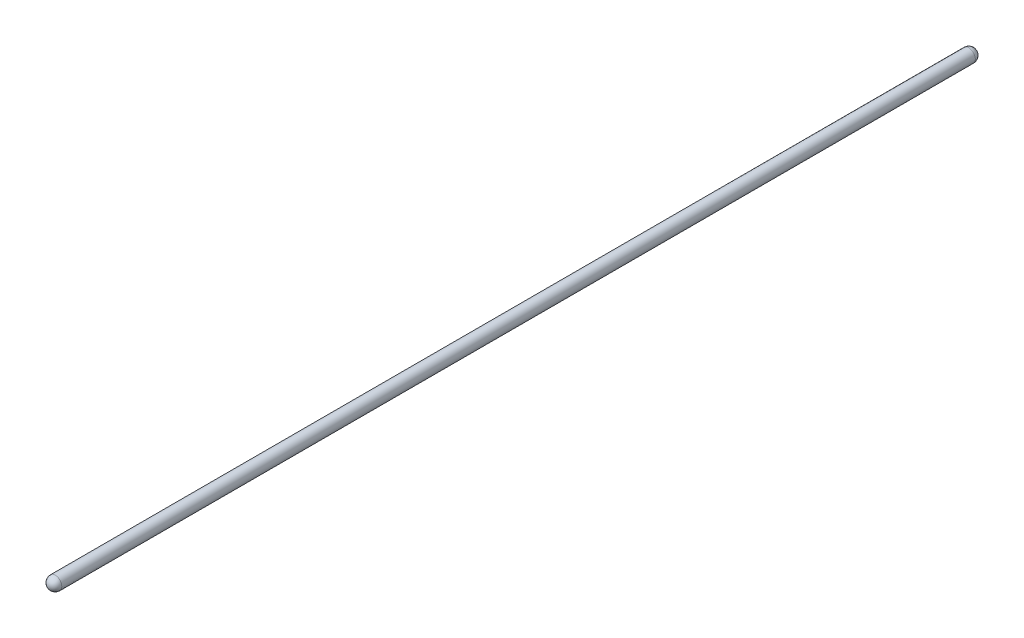
from build123d import *


with BuildPart() as part:
    # Sketch1 → Revolve1 (revolve)
    with BuildSketch(Plane(origin=(0, 0, 0), x_dir=(1, 0, 0), z_dir=(0, 1, 0))):
        with BuildLine():
            Line((9.525, 0), (9.525, -1327.76976))
            ThreePointArc((9.525, -1327.76976), (6.735192091, -1334.504952091), (0, -1337.29476))
            Line((0, -1337.29476), (0, 9.525))
            ThreePointArc((0, 9.525), (6.735192091, 6.735192091), (9.525, 0))
        make_face()
    revolve(axis=Axis((0, 0, -9.525), (0, 0, 1)))


solid = part.part
